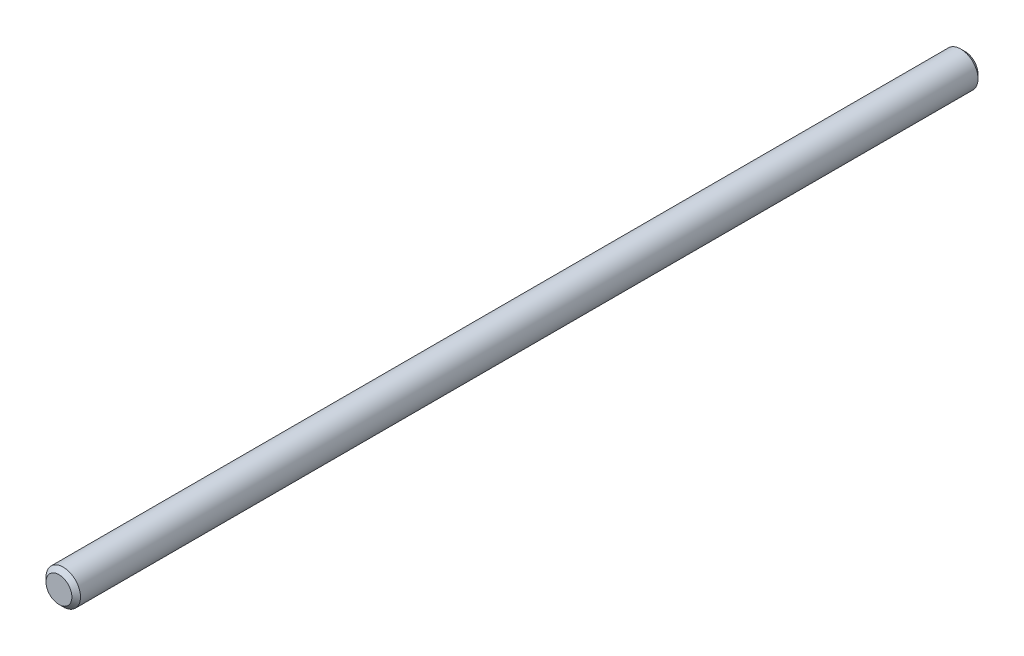
from build123d import *

# Parameters (mm, degrees)
SKETCH1_R           = 2
BOSS_EXTRUDE1_DEPTH = 52.5
CHAMFER1_SIZE       = 0.5


with BuildPart() as part:
    # Sketch1 → Boss-Extrude1 (new body, symmetric)
    with BuildSketch(Plane.XY):
        Circle(SKETCH1_R)
    extrude(amount=BOSS_EXTRUDE1_DEPTH, both=True)

    # Chamfer1
    chamfer1_edges = [part.edges().sort_by_distance(p)[0] for p in [
        (-2, 0, -52.5),
        (-2, 0, 52.5),
    ]]
    chamfer(chamfer1_edges, length=CHAMFER1_SIZE)


solid = part.part
